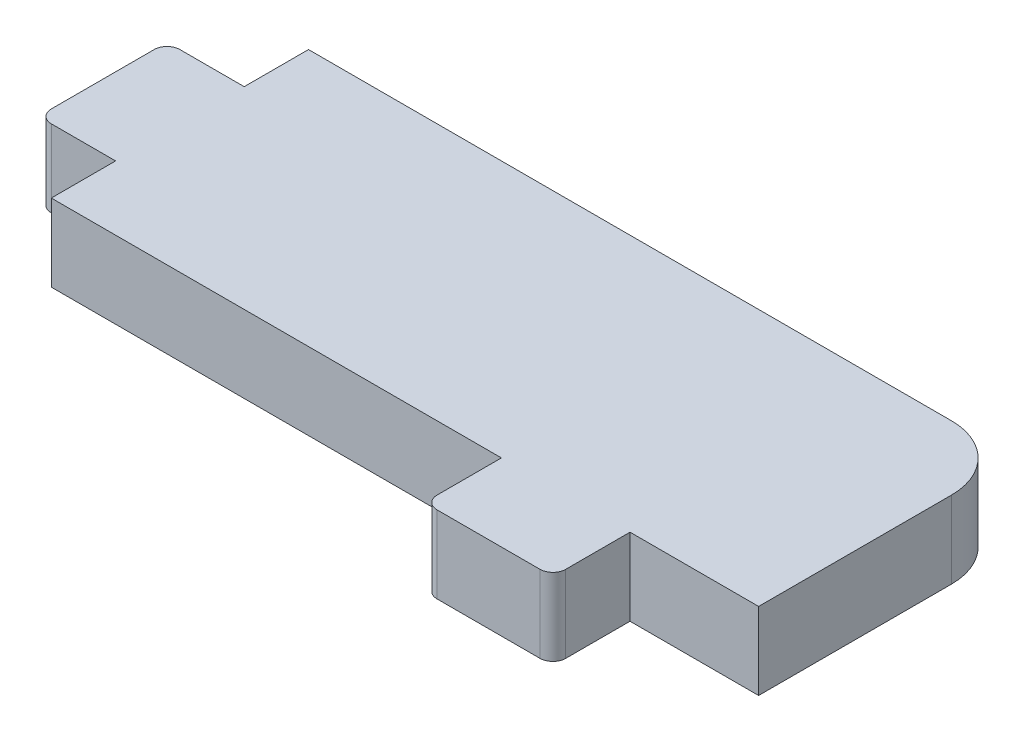
from build123d import *

# Parameters (mm, degrees)
SKETCH1_W              = 55
SKETCH1_H              = 20
BOSS_EXTRUDE1_DEPTH    = 6
SKETCH234_W            = 10
SKETCH234_H            = 6
BOSS_EXTRUDE234_DEPTH  = 6
FILLET134_R            = 1
SKETCH2342_W           = 10
SKETCH2342_H           = 6
BOSS_EXTRUDE2342_DEPTH = 6
FILLET1342_R           = 1
FILLET1343_R           = 5


with BuildPart() as part:
    # Sketch1 → Boss-Extrude1 (new body)
    with BuildSketch(Plane(origin=(0, 0, 0), x_dir=(1, 0, 0), z_dir=(0, 1, 0))):
        Rectangle(SKETCH1_W, SKETCH1_H)
    extrude(amount=BOSS_EXTRUDE1_DEPTH)

    # Sketch234 → Boss-Extrude234 (add)
    with BuildSketch(Plane(origin=(13.267778608, 6, 10), x_dir=(-1, 0, 0), z_dir=(0, 0, 1))):
        with Locations((0.767778608, 3)):
            Rectangle(SKETCH234_W, SKETCH234_H)
    extrude(amount=BOSS_EXTRUDE234_DEPTH)

    # Fillet134
    fillet134_edges = [part.edges().sort_by_distance(p)[0] for p in [
        (17.5, 3, 16),
        (7.5, 3, 16),
    ]]
    fillet(fillet134_edges, radius=FILLET134_R)

    # Sketch2342 → Boss-Extrude2342 (add)
    with BuildSketch(Plane(origin=(-27.5, 0, -0.767778608), x_dir=(0, 0, 1), z_dir=(-1, 0, 0))):
        with Locations((0.767778608, 3)):
            Rectangle(SKETCH2342_W, SKETCH2342_H)
    extrude(amount=BOSS_EXTRUDE2342_DEPTH)

    # Fillet1342
    fillet1342_edges = [part.edges().sort_by_distance(p)[0] for p in [
        (-33.5, 3, -5),
        (-33.5, 3, 5),
    ]]
    fillet(fillet1342_edges, radius=FILLET1342_R)

    # Fillet1343
    fillet1343_edges = [part.edges().sort_by_distance(p)[0] for p in [
        (27.5, 3, -10),
    ]]
    fillet(fillet1343_edges, radius=FILLET1343_R)


solid = part.part
